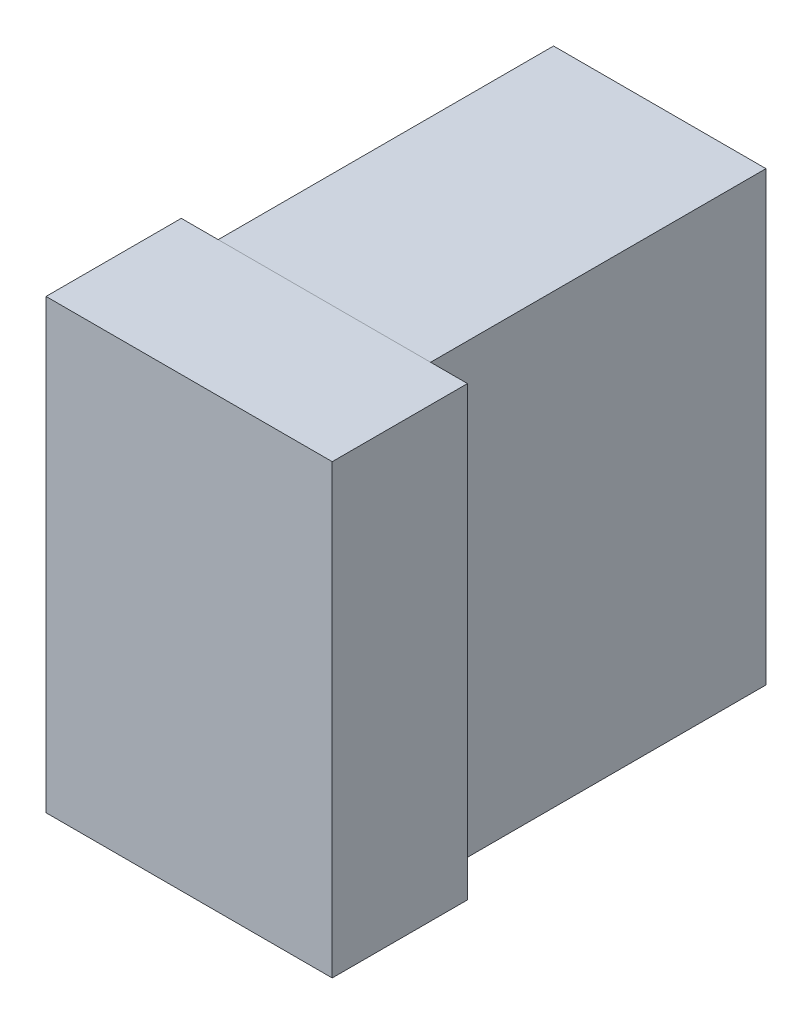
from build123d import *

# Parameters (mm, degrees)
SKETCH_1_W      = 12.8
SKETCH_1_H      = 6.05
EXTRUDE_1_DEPTH = 20
SKETCH_2_W      = 9.5
SKETCH_2_H      = 15
EXTRUDE_2_DEPTH = 20


with BuildPart() as part:
    # 草图1 → 凸台-拉伸1 (new body)
    with BuildSketch(Plane(origin=(0, 0, 0), x_dir=(1, 0, 0), z_dir=(0, 1, 0))):
        with Locations((0, 3.025)):
            Rectangle(SKETCH_1_W, SKETCH_1_H)
    extrude(amount=EXTRUDE_1_DEPTH)


with BuildPart() as body_2:
    # 草图2 → 凸台-拉伸2 (new body)
    with BuildSketch(Plane.XZ):
        with Locations((0, -13.55)):
            Rectangle(SKETCH_2_W, SKETCH_2_H)
    extrude(amount=-EXTRUDE_2_DEPTH)


solid = Compound([part.part, body_2.part])
